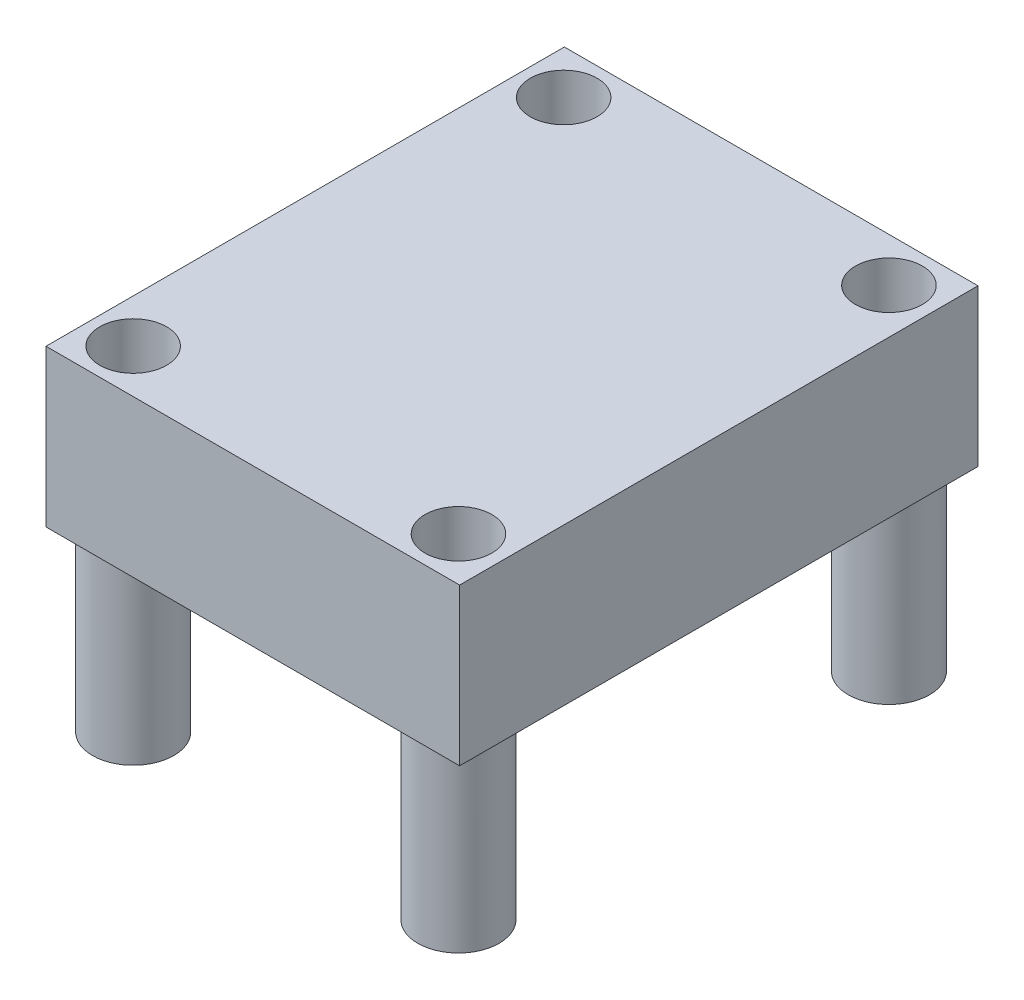
from build123d import *

# Parameters (mm, degrees)
SKETCH1_W               = 20.2692
SKETCH1_H               = 25.4
BOSS_EXTRUDE1_DEPTH     = 7.6708
SKETCH2_R               = 1.9939
SKETCH2_R_2             = 1.6383
BOSS_EXTRUDE2_DEPTH     = 8.7122
SKETCH3_R               = 1.6383
CUT_EXTRUDE1_DEPTH      = 1
CUT_EXTRUDE1_DEPTH_BACK = 17.383


with BuildPart() as part:
    # Sketch1 → Boss-Extrude1 (new body)
    with BuildSketch(Plane(origin=(0, 0, 0), x_dir=(1, 0, 0), z_dir=(0, 1, 0))):
        with Locations((0.995181162, -4.637001603)):
            Rectangle(SKETCH1_W, SKETCH1_H)
    extrude(amount=BOSS_EXTRUDE1_DEPTH)

    # Sketch2 → Boss-Extrude2 (add)
    with BuildSketch(Plane(origin=(0, 0, 0), x_dir=(-1, 0, 0), z_dir=(0, -1, 0))):
        with Locations((7.01266761, -15.1920941)):
            Circle(SKETCH2_R)
        with Locations((7.01266761, -15.1920941)):
            Circle(SKETCH2_R_2, mode=Mode.SUBTRACT)
        with Locations((-8.925132573, -15.1920941)):
            Circle(SKETCH2_R)
        with Locations((-8.925132573, -15.1920941)):
            Circle(SKETCH2_R_2, mode=Mode.SUBTRACT)
        with Locations((-8.925132573, 5.902511421)):
            Circle(SKETCH2_R)
        with Locations((-8.925132573, 5.902511421)):
            Circle(SKETCH2_R_2, mode=Mode.SUBTRACT)
        with Locations((7.01266761, 5.902511421)):
            Circle(SKETCH2_R)
        with Locations((7.01266761, 5.902511421)):
            Circle(SKETCH2_R_2, mode=Mode.SUBTRACT)
    extrude(amount=BOSS_EXTRUDE2_DEPTH)

    # Sketch3 → Cut-Extrude1 (cut, two sides)
    with BuildSketch(Plane(origin=(0, 7.6708, 0), x_dir=(1, 0, 0), z_dir=(0, 1, 0))) as cut_extrude1_sk:
        with Locations((8.925132573, 5.902511421)):
            Circle(SKETCH3_R)
        with Locations((-7.01266761, 5.902511421)):
            Circle(SKETCH3_R)
        with Locations((8.925132573, -15.1920941)):
            Circle(SKETCH3_R)
        with Locations((-7.01266761, -15.1920941)):
            Circle(SKETCH3_R)
    extrude(amount=CUT_EXTRUDE1_DEPTH, mode=Mode.SUBTRACT)
    extrude(cut_extrude1_sk.sketch, amount=-CUT_EXTRUDE1_DEPTH_BACK, mode=Mode.SUBTRACT)


solid = part.part
